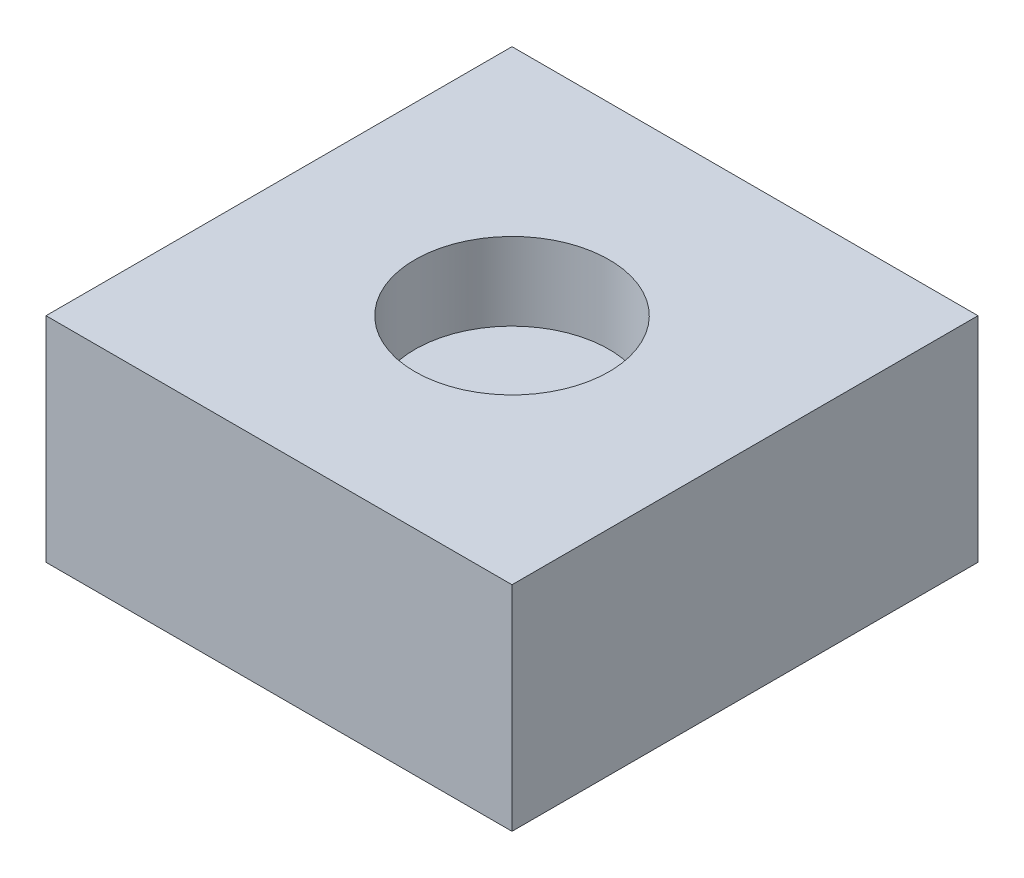
from build123d import *

# Parameters (mm, degrees)
SKETCH1_W           = 12
SKETCH1_H           = 12
BOSS_EXTRUDE1_DEPTH = 5.5
SKETCH2_R           = 2.5
CUT_EXTRUDE1_DEPTH  = 2
SKETCH4_R           = 1
CUT_EXTRUDE3_DEPTH  = 2
FILLET2_R           = 1


with BuildPart() as part:
    # Sketch1 → Boss-Extrude1 (new body)
    with BuildSketch(Plane(origin=(0, 0, 0), x_dir=(1, 0, 0), z_dir=(0, 1, 0))):
        Rectangle(SKETCH1_W, SKETCH1_H)
    extrude(amount=BOSS_EXTRUDE1_DEPTH)

    # Sketch2 → Cut-Extrude1 (cut)
    with BuildSketch(Plane(origin=(0, 5.5, 0), x_dir=(1, 0, 0), z_dir=(0, 1, 0))):
        Circle(SKETCH2_R)
    extrude(amount=-CUT_EXTRUDE1_DEPTH, mode=Mode.SUBTRACT)

    # Sketch4 → Cut-Extrude3 (cut)
    with BuildSketch(Plane.XZ):
        Circle(SKETCH4_R)
    extrude(amount=-CUT_EXTRUDE3_DEPTH, mode=Mode.SUBTRACT)

    # Fillet2
    fillet2_edges = [part.edges().sort_by_distance(p)[0] for p in [
        (-1, 2, 0),
    ]]
    fillet(fillet2_edges, radius=FILLET2_R)


solid = part.part
